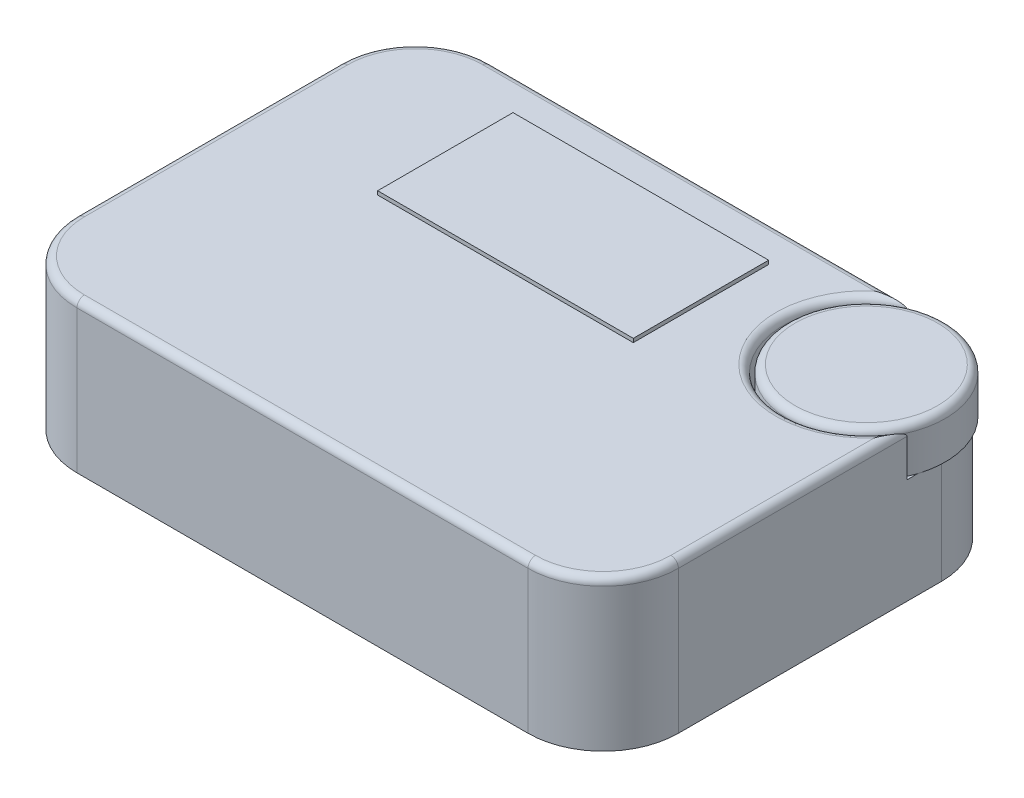
from build123d import *

# Parameters (mm, degrees)
SKETCH1_W           = 80
SKETCH1_H           = 55
BOSS_EXTRUDE2_DEPTH = 20
FILLET1_R           = 10
SKETCH3_R           = 11
CUT_EXTRUDE2_DEPTH  = 6
SKETCH5_W           = 34
SKETCH5_H           = 18
CUT_EXTRUDE3_DEPTH  = 2
SKETCH6_R           = 10.5
BOSS_EXTRUDE3_DEPTH = 6
FILLET2_R           = 1
FILLET3_R           = 1
SKETCH7_W           = 34
SKETCH7_H           = 18
BOSS_EXTRUDE4_DEPTH = 2.5


with BuildPart() as part:
    # Sketch1 → Boss-Extrude2 (new body)
    with BuildSketch(Plane(origin=(0, 0, 0), x_dir=(1, 0, 0), z_dir=(0, 1, 0))):
        Rectangle(SKETCH1_W, SKETCH1_H)
    extrude(amount=BOSS_EXTRUDE2_DEPTH)

    # Fillet1
    fillet1_edges = [part.edges().sort_by_distance(p)[0] for p in [
        (40, 10, 27.5),
        (-40, 10, 27.5),
        (-40, 10, -27.5),
        (40, 10, -27.5),
    ]]
    fillet(fillet1_edges, radius=FILLET1_R)

    # Sketch3 → Cut-Extrude2 (cut)
    with BuildSketch(Plane(origin=(0, 20, 0), x_dir=(1, 0, 0), z_dir=(0, 1, 0))):
        with Locations((30, 17.5)):
            Circle(SKETCH3_R)
    extrude(amount=-CUT_EXTRUDE2_DEPTH, mode=Mode.SUBTRACT)

    # Sketch5 → Cut-Extrude3 (cut)
    with BuildSketch(Plane(origin=(0, 20, 0), x_dir=(1, 0, 0), z_dir=(0, 1, 0))):
        with Locations((-5, 13.5)):
            Rectangle(SKETCH5_W, SKETCH5_H)
    extrude(amount=-CUT_EXTRUDE3_DEPTH, mode=Mode.SUBTRACT)

    # Sketch6 → Boss-Extrude3 (add)
    with BuildSketch(Plane(origin=(0, 14, 0), x_dir=(1, 0, 0), z_dir=(0, 1, 0))):
        with Locations((30, 17.5)):
            Circle(SKETCH6_R)
    extrude(amount=BOSS_EXTRUDE3_DEPTH)

    # Fillet2
    fillet2_edges = [part.edges().sort_by_distance(p)[0] for p in [
        (-40, 20, 0),
        (40, 20, 2.291287847),
        (0, 20, 27.5),
        (-37.071067812, 20, 24.571067812),
        (37.071067812, 20, 24.571067812),
        (-37.071067812, 20, -24.571067812),
        (-2.291287847, 20, -27.5),
        (22.221825407, 20, -9.721825407),
    ]]
    fillet(fillet2_edges, radius=FILLET2_R)

    # Fillet3
    fillet3_edges = [part.edges().sort_by_distance(p)[0] for p in [
        (19.5, 20, -17.5),
    ]]
    fillet(fillet3_edges, radius=FILLET3_R)

    # Sketch7 → Boss-Extrude4 (add)
    with BuildSketch(Plane(origin=(0, 18, 0), x_dir=(1, 0, 0), z_dir=(0, 1, 0))):
        with Locations((-5, 13.5)):
            Rectangle(SKETCH7_W, SKETCH7_H)
    extrude(amount=BOSS_EXTRUDE4_DEPTH)


solid = part.part
